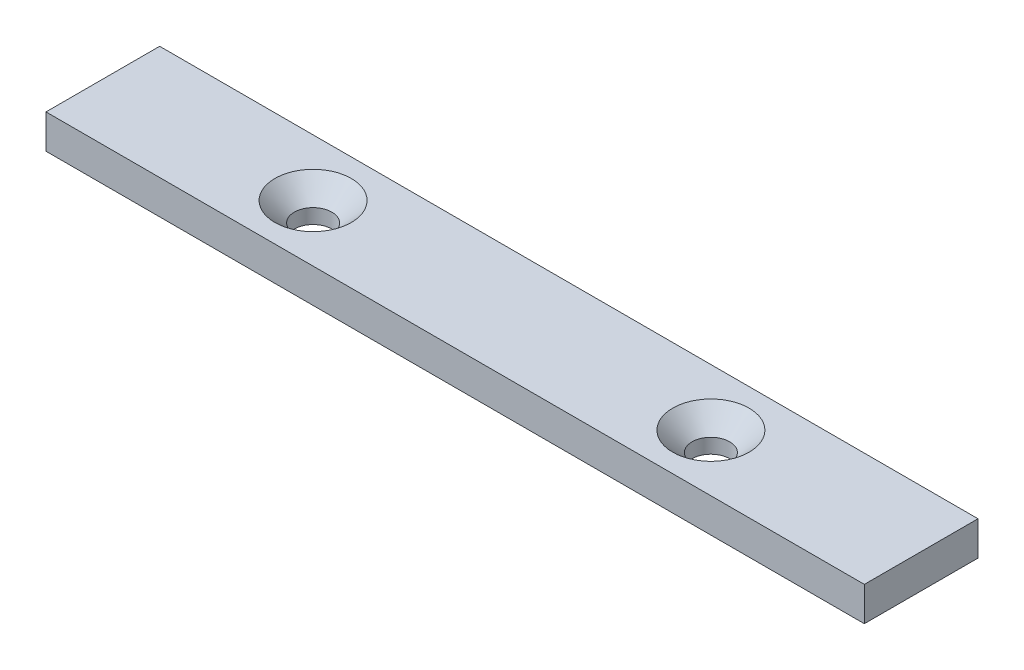
from build123d import *

# Parameters (mm, degrees)
SKETCH1_W                           = 144
SKETCH1_H                           = 20
EXTRUDE1_DEPTH                      = 6
ESCAREADO_PARA_SFHCS_M61_AT_2_COUNT = 2
ESCAREADO_PARA_SFHCS_M61_AT_2_PITCH = 70


with BuildPart() as part:
    # Sketch1 → Extrude1 (new body)
    with BuildSketch(Plane(origin=(0, 0, 0), x_dir=(1, 0, 0), z_dir=(0, 1, 0))):
        Rectangle(SKETCH1_W, SKETCH1_H)
    extrude(amount=EXTRUDE1_DEPTH)

    # Esboço1 → Escareado para SFHCS M61 (revolve, cut)
    with BuildSketch(Plane(origin=(-35, 6, 0), x_dir=(0, 0, 1), z_dir=(1, 0, 0))):
        Polygon((0, 0), (0, 6), (3.3, 6), (3.3, 3.42), (6.72, 0), align=None)
    escareado_para_sfhcs_m61 = revolve(axis=Axis((-35, 12.35, 0), (0, -1, 0)), mode=Mode.SUBTRACT)

    # Escareado para SFHCS M61 at 2: Escareado para SFHCS M61 ×2
    with Locations(*[(i * ESCAREADO_PARA_SFHCS_M61_AT_2_PITCH, 0, 0) for i in range(1, ESCAREADO_PARA_SFHCS_M61_AT_2_COUNT)]):
        add(escareado_para_sfhcs_m61, mode=Mode.SUBTRACT)


solid = part.part
